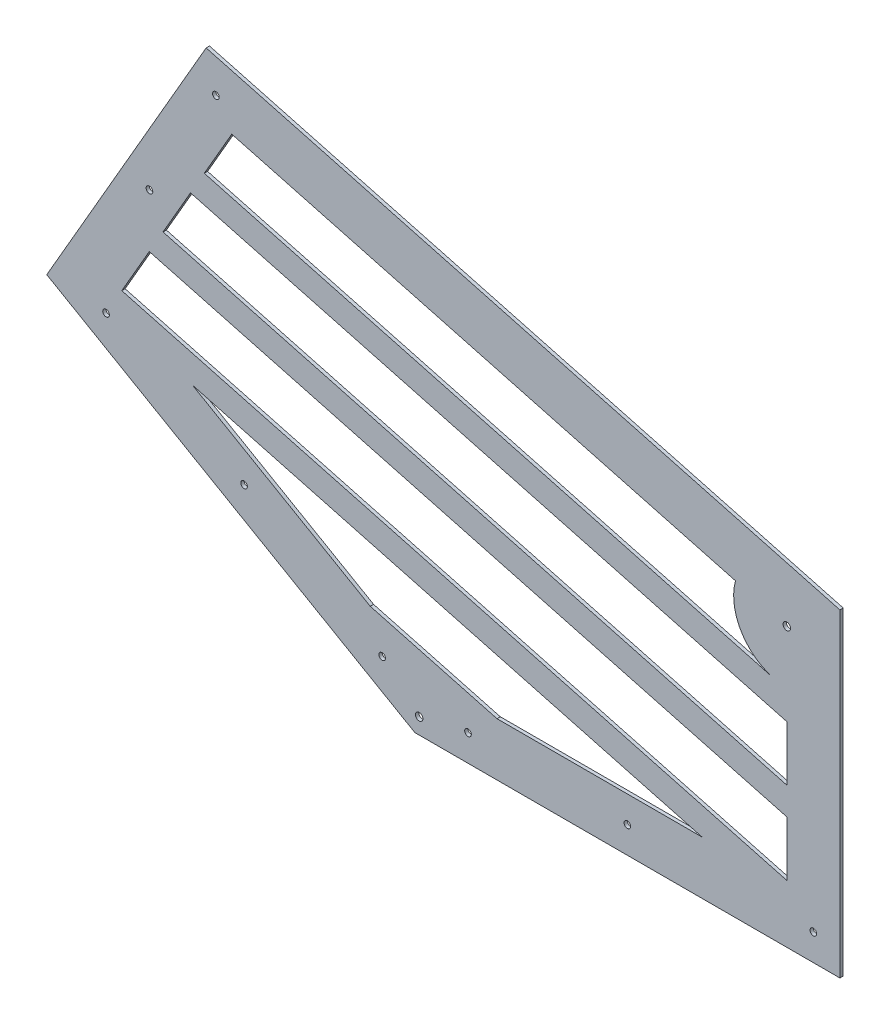
from build123d import *

# Parameters (mm, degrees)
SKETCH_1_R      = 1.7859375
SKETCH_1_R_2    = 1.5875
EXTRUDE_1_DEPTH = 1.5875


with BuildPart() as part:
    # 스케치1 → 보스-돌출1 (new body)
    with BuildSketch(Plane.XY):
        Polygon((0, 0), (203.2, 0), (203.2, 152.4), (-99.776362049, 233.582271537), (-175.976362049, 101.6), align=None)
        with Locations((2.041772846, 7.62)):
            Circle(SKETCH_1_R, mode=Mode.SUBTRACT)
        with Locations((177.8, 132.909894505)):
            Circle(SKETCH_1_R, mode=Mode.SUBTRACT)
        with Locations((190.5, 12.7)):
            Circle(SKETCH_1_R_2, mode=Mode.SUBTRACT)
        with Locations((101.6, 12.7)):
            Circle(SKETCH_1_R_2, mode=Mode.SUBTRACT)
        with Locations((25.4, 12.7)):
            Circle(SKETCH_1_R_2, mode=Mode.SUBTRACT)
        with Locations((-147.629316793, 99.898522628)):
            Circle(SKETCH_1_R_2, mode=Mode.SUBTRACT)
        with Locations((-81.638181024, 61.798522628)):
            Circle(SKETCH_1_R_2, mode=Mode.SUBTRACT)
        with Locations((-15.647045256, 23.698522628)):
            Circle(SKETCH_1_R_2, mode=Mode.SUBTRACT)
        with Locations((-95.127839421, 216.233748909)):
            Circle(SKETCH_1_R_2, mode=Mode.SUBTRACT)
        with Locations((-126.877839421, 161.241135768)):
            Circle(SKETCH_1_R_2, mode=Mode.SUBTRACT)
        Polygon((-106.301504082, 90.702595672), (-21.311447622, 41.633563696), (39.27303688, 25.4), (137.411100831, 25.4), align=None, mode=Mode.SUBTRACT)
        Polygon((177.8, 27.725834576), (177.8, 54.021849558), (-126.968392014, 135.684294077), (-140.116399505, 112.911277084), align=None, mode=Mode.SUBTRACT)
        with BuildLine():
            Line((-100.672377031, 181.230328063), (171.225996254, 108.375378518))
            ThreePointArc((171.225996254, 108.375378518), (155.802954744, 120.209894505), (153.265484012, 139.483898251))
            Line((153.265484012, 139.483898251), (-87.52436954, 204.003345056))
            Line((-87.52436954, 204.003345056), (-100.672377031, 181.230328063))
        make_face(mode=Mode.SUBTRACT)
        Polygon((-107.246380777, 169.843819566), (177.8, 93.465872032), (177.8, 67.169857049), (-120.394388268, 147.070802573), align=None, mode=Mode.SUBTRACT)
    extrude(amount=EXTRUDE_1_DEPTH)


solid = part.part
